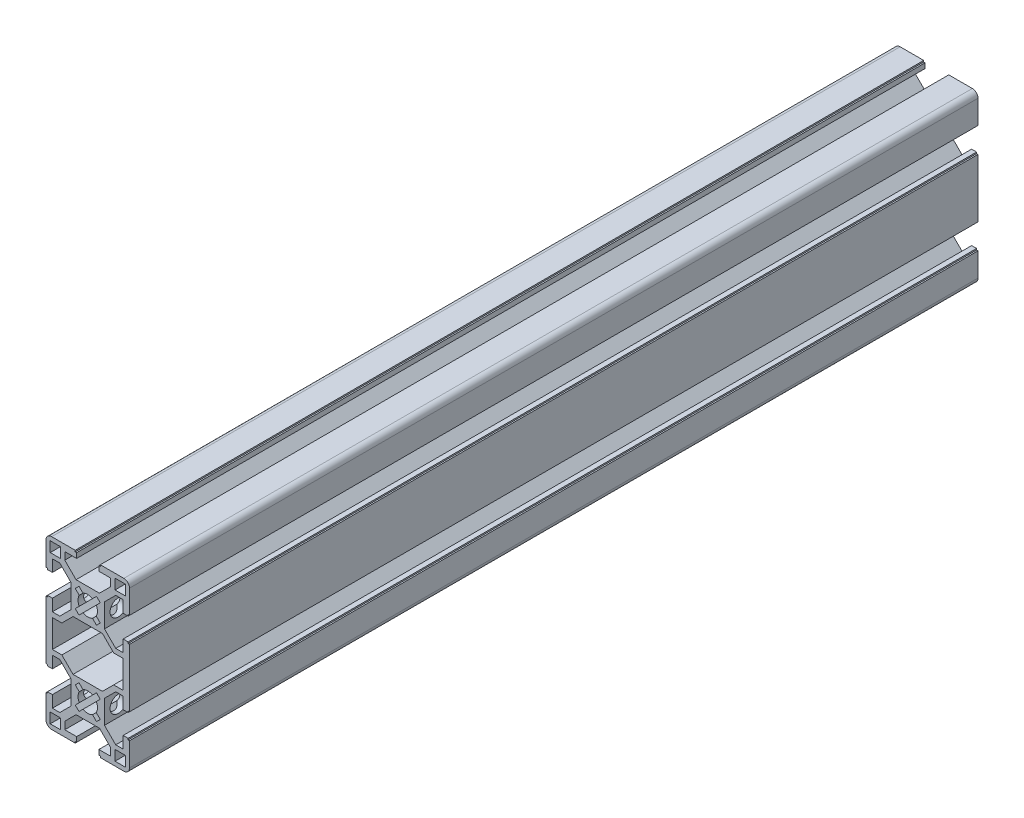
from build123d import *

# Parameters (mm, degrees)
SKETCH2_W           = 3.683
SKETCH2_H           = 3.683
BOSS_EXTRUDE1_DEPTH = 304.8
SKETCH4_R           = 3
CUT_EXTRUDE2_DEPTH  = 21
SKETCH6_R           = 2
CUT_EXTRUDE3_DEPTH  = 42


with BuildPart() as part:
    # Sketch2 → Boss-Extrude1 (new body)
    with BuildSketch(Plane.XY):
        with BuildLine():
            Line((-6, 10.796051224), (-6, 15))
            Line((-6, 15), (-6, 19.203948776))
            Line((-6, 19.203948776), (-10.046051224, 23.25))
            Line((-10.046051224, 23.25), (-12.714, 23.25))
            Line((-12.714, 23.25), (-12.714, 19))
            Line((-12.714, 19), (-14.5, 19))
            Line((-14.5, 19), (-14.5, 19.5))
            Line((-14.5, 19.5), (-15, 19.5))
            Line((-15, 19.5), (-15, 27.968))
            ThreePointArc((-15, 27.968), (-14.404840979, 29.404840979), (-12.968, 30))
            Line((-12.968, 30), (-4.5, 30))
            Line((-4.5, 30), (-4.5, 29.5))
            Line((-4.5, 29.5), (-4, 29.5))
            Line((-4, 29.5), (-4, 27.714))
            Line((-4, 27.714), (-8.25, 27.714))
            Line((-8.25, 27.714), (-8.25, 25.046051224))
            Line((-8.25, 25.046051224), (-4.203948776, 21))
            Line((-4.203948776, 21), (0, 21))
            Line((0, 21), (4.203948776, 21))
            Line((4.203948776, 21), (8.25, 25.046051224))
            Line((8.25, 25.046051224), (8.25, 27.714))
            Line((8.25, 27.714), (4, 27.714))
            Line((4, 27.714), (4, 29.5))
            Line((4, 29.5), (4.5, 29.5))
            Line((4.5, 29.5), (4.5, 30))
            Line((4.5, 30), (12.968, 30))
            ThreePointArc((12.968, 30), (14.404840979, 29.404840979), (15, 27.968))
            Line((15, 27.968), (15, 19.5))
            Line((15, 19.5), (14.5, 19.5))
            Line((14.5, 19.5), (14.5, 19))
            Line((14.5, 19), (12.714, 19))
            Line((12.714, 19), (12.714, 23.25))
            Line((12.714, 23.25), (10.046051224, 23.25))
            Line((10.046051224, 23.25), (6, 19.203948776))
            Line((6, 19.203948776), (6, 15))
            Line((6, 15), (6, 10.796051224))
            Line((6, 10.796051224), (10.046051224, 6.75))
            Line((10.046051224, 6.75), (12.714, 6.75))
            Line((12.714, 6.75), (12.714, 11))
            Line((12.714, 11), (14.5, 11))
            Line((14.5, 11), (14.5, 10.5))
            Line((14.5, 10.5), (15, 10.5))
            Line((15, 10.5), (15, -10.5))
            Line((15, -10.5), (14.5, -10.5))
            Line((14.5, -10.5), (14.5, -11))
            Line((14.5, -11), (12.714, -11))
            Line((12.714, -11), (12.714, -6.75))
            Line((12.714, -6.75), (10.046051224, -6.75))
            Line((10.046051224, -6.75), (6, -10.796051224))
            Line((6, -10.796051224), (6, -15))
            Line((6, -15), (6, -19.203948776))
            Line((6, -19.203948776), (10.046051224, -23.25))
            Line((10.046051224, -23.25), (12.714, -23.25))
            Line((12.714, -23.25), (12.714, -19))
            Line((12.714, -19), (14.5, -19))
            Line((14.5, -19), (14.5, -19.5))
            Line((14.5, -19.5), (15, -19.5))
            Line((15, -19.5), (15, -27.968))
            ThreePointArc((15, -27.968), (14.404840979, -29.404840979), (12.968, -30))
            Line((12.968, -30), (4.5, -30))
            Line((4.5, -30), (4.5, -29.5))
            Line((4.5, -29.5), (4, -29.5))
            Line((4, -29.5), (4, -27.714))
            Line((4, -27.714), (8.25, -27.714))
            Line((8.25, -27.714), (8.25, -25.046051224))
            Line((8.25, -25.046051224), (4.203948776, -21))
            Line((4.203948776, -21), (0, -21))
            Line((0, -21), (-4.203948776, -21))
            Line((-4.203948776, -21), (-8.25, -25.046051224))
            Line((-8.25, -25.046051224), (-8.25, -27.714))
            Line((-8.25, -27.714), (-4, -27.714))
            Line((-4, -27.714), (-4, -29.5))
            Line((-4, -29.5), (-4.5, -29.5))
            Line((-4.5, -29.5), (-4.5, -30))
            Line((-4.5, -30), (-12.968, -30))
            ThreePointArc((-12.968, -30), (-14.404840979, -29.404840979), (-15, -27.968))
            Line((-15, -27.968), (-15, -19.5))
            Line((-15, -19.5), (-14.5, -19.5))
            Line((-14.5, -19.5), (-14.5, -19))
            Line((-14.5, -19), (-12.714, -19))
            Line((-12.714, -19), (-12.714, -23.25))
            Line((-12.714, -23.25), (-10.046051224, -23.25))
            Line((-10.046051224, -23.25), (-6, -19.203948776))
            Line((-6, -19.203948776), (-6, -15))
            Line((-6, -15), (-6, -10.796051224))
            Line((-6, -10.796051224), (-10.046051224, -6.75))
            Line((-10.046051224, -6.75), (-12.714, -6.75))
            Line((-12.714, -6.75), (-12.714, -11))
            Line((-12.714, -11), (-14.5, -11))
            Line((-14.5, -11), (-14.5, -10.5))
            Line((-14.5, -10.5), (-15, -10.5))
            Line((-15, -10.5), (-15, 10.5))
            Line((-15, 10.5), (-14.5, 10.5))
            Line((-14.5, 10.5), (-14.5, 11))
            Line((-14.5, 11), (-12.714, 11))
            Line((-12.714, 11), (-12.714, 6.75))
            Line((-12.714, 6.75), (-10.046051224, 6.75))
            Line((-10.046051224, 6.75), (-6, 10.796051224))
        make_face()
        with Locations((-11.6345, -26.6345)):
            Rectangle(SKETCH2_W, SKETCH2_H, mode=Mode.SUBTRACT)
        with BuildLine():
            Line((-3.143089642, 10.509871939), (-4.490128061, 11.856910358))
            Line((-4.490128061, 11.856910358), (-3.054983438, 13.29205498))
            ThreePointArc((-3.054983438, 13.29205498), (-3.5, 15), (-3.054983438, 16.70794502))
            Line((-3.054983438, 16.70794502), (-4.490128061, 18.143089642))
            Line((-4.490128061, 18.143089642), (-3.143089642, 19.490128061))
            Line((-3.143089642, 19.490128061), (-1.70794502, 18.054983438))
            ThreePointArc((-1.70794502, 18.054983438), (0, 18.5), (1.70794502, 18.054983438))
            Line((1.70794502, 18.054983438), (3.143089642, 19.490128061))
            Line((3.143089642, 19.490128061), (4.490128061, 18.143089642))
            Line((4.490128061, 18.143089642), (3.054983438, 16.70794502))
            ThreePointArc((3.054983438, 16.70794502), (3.5, 15), (3.054983438, 13.29205498))
            Line((3.054983438, 13.29205498), (4.490128061, 11.856910358))
            Line((4.490128061, 11.856910358), (3.143089642, 10.509871939))
            Line((3.143089642, 10.509871939), (1.70794502, 11.945016562))
            ThreePointArc((1.70794502, 11.945016562), (0, 11.5), (-1.70794502, 11.945016562))
            Line((-1.70794502, 11.945016562), (-3.143089642, 10.509871939))
        make_face(mode=Mode.SUBTRACT)
        Polygon((-5.28157951, 9), (-9.30957951, 4.972), (-12.714, 4.972), (-12.714, -4.972), (-9.30957951, -4.972), (-5.28157951, -9), (5.28157951, -9), (9.30957951, -4.972), (12.714, -4.972), (12.714, 4.972), (9.30957951, 4.972), (5.28157951, 9), align=None, mode=Mode.SUBTRACT)
        with Locations((-11.6345, 26.6345)):
            Rectangle(SKETCH2_W, SKETCH2_H, mode=Mode.SUBTRACT)
        with BuildLine():
            Line((3.143089642, -10.509871939), (4.490128061, -11.856910358))
            Line((4.490128061, -11.856910358), (3.054983438, -13.29205498))
            ThreePointArc((3.054983438, -13.29205498), (3.5, -15), (3.054983438, -16.70794502))
            Line((3.054983438, -16.70794502), (4.490128061, -18.143089642))
            Line((4.490128061, -18.143089642), (3.143089642, -19.490128061))
            Line((3.143089642, -19.490128061), (1.70794502, -18.054983438))
            ThreePointArc((1.70794502, -18.054983438), (0, -18.5), (-1.70794502, -18.054983438))
            Line((-1.70794502, -18.054983438), (-3.143089642, -19.490128061))
            Line((-3.143089642, -19.490128061), (-4.490128061, -18.143089642))
            Line((-4.490128061, -18.143089642), (-3.054983438, -16.70794502))
            ThreePointArc((-3.054983438, -16.70794502), (-3.5, -15), (-3.054983438, -13.29205498))
            Line((-3.054983438, -13.29205498), (-4.490128061, -11.856910358))
            Line((-4.490128061, -11.856910358), (-3.143089642, -10.509871939))
            Line((-3.143089642, -10.509871939), (-1.70794502, -11.945016562))
            ThreePointArc((-1.70794502, -11.945016562), (0, -11.5), (1.70794502, -11.945016562))
            Line((1.70794502, -11.945016562), (3.143089642, -10.509871939))
        make_face(mode=Mode.SUBTRACT)
        with Locations((11.6345, 26.6345)):
            Rectangle(SKETCH2_W, SKETCH2_H, mode=Mode.SUBTRACT)
        with Locations((11.6345, -26.6345)):
            Rectangle(SKETCH2_W, SKETCH2_H, mode=Mode.SUBTRACT)
    extrude(amount=BOSS_EXTRUDE1_DEPTH)

    # Sketch4 → Cut-Extrude2 (cut)
    with BuildSketch(Plane.ZY.offset(6)):
        with Locations((299.8, 15)):
            Circle(SKETCH4_R)
        with Locations((299.8, -15)):
            Circle(SKETCH4_R)
    extrude(amount=-CUT_EXTRUDE2_DEPTH, mode=Mode.SUBTRACT)

    # Sketch6 → Cut-Extrude3 (cut)
    with BuildSketch(Plane.XZ.offset(21)):
        with Locations((0, 7.5)):
            Circle(SKETCH6_R)
    extrude(amount=-CUT_EXTRUDE3_DEPTH, mode=Mode.SUBTRACT)


solid = part.part
